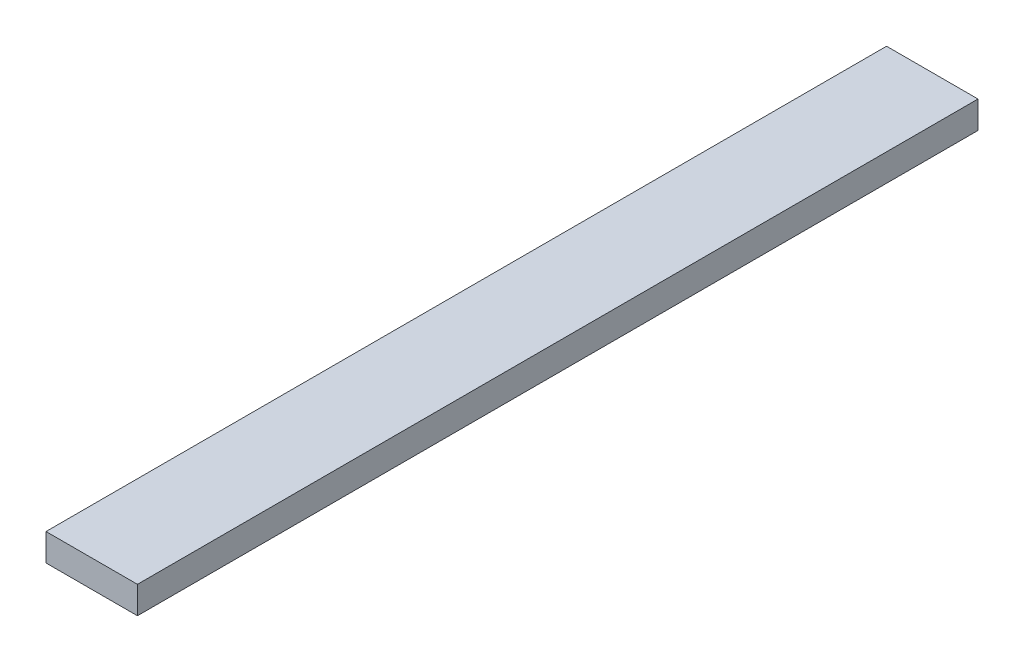
from build123d import *

# Parameters (mm, degrees)
ESQUISSE1_W        = 20.124611798
ESQUISSE1_H        = 6
BOSS_EXTRU_1_DEPTH = 185


with BuildPart() as part:
    # Esquisse1 → Boss.-Extru.1 (new body)
    with BuildSketch(Plane.XY):
        Rectangle(ESQUISSE1_W, ESQUISSE1_H)
    extrude(amount=BOSS_EXTRU_1_DEPTH)


solid = part.part
